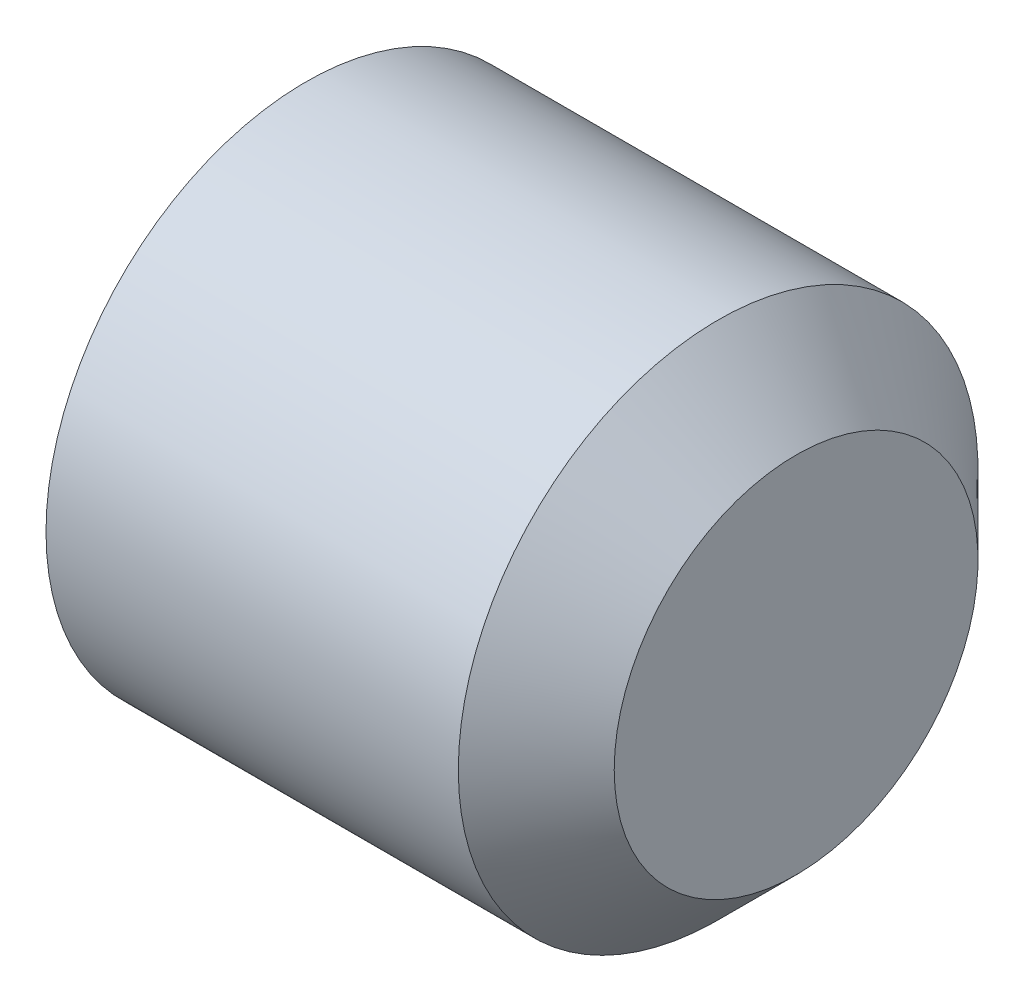
from build123d import *

# Parameters (mm, degrees)
CUT_EXTRUDE1_DEPTH = 2


with BuildPart() as part:
    # Sketch1 → Revolve1 (revolve)
    with BuildSketch(Plane.XY):
        Polygon((5, 0), (5, -1.75), (4.25, -2.5), (0.283190307, -2.5), (0, -2.0095), (0, -1.443375673), (0.833333333, 0), align=None)
    revolve(axis=Axis((0.833333333, 0, 0), (1, 0, 0)))

    # Sketch2 → Cut-Extrude1 (cut)
    with BuildSketch(Plane(origin=(0, 0, 0), x_dir=(0, 0, -1), z_dir=(1, 0, 0))):
        Polygon((-1.443375673, 0), (-0.721687836, -1.25), (0.721687836, -1.25), (1.443375673, 0), (0.721687836, 1.25), (-0.721687836, 1.25), align=None)
    extrude(amount=CUT_EXTRUDE1_DEPTH, mode=Mode.SUBTRACT)


solid = part.part
